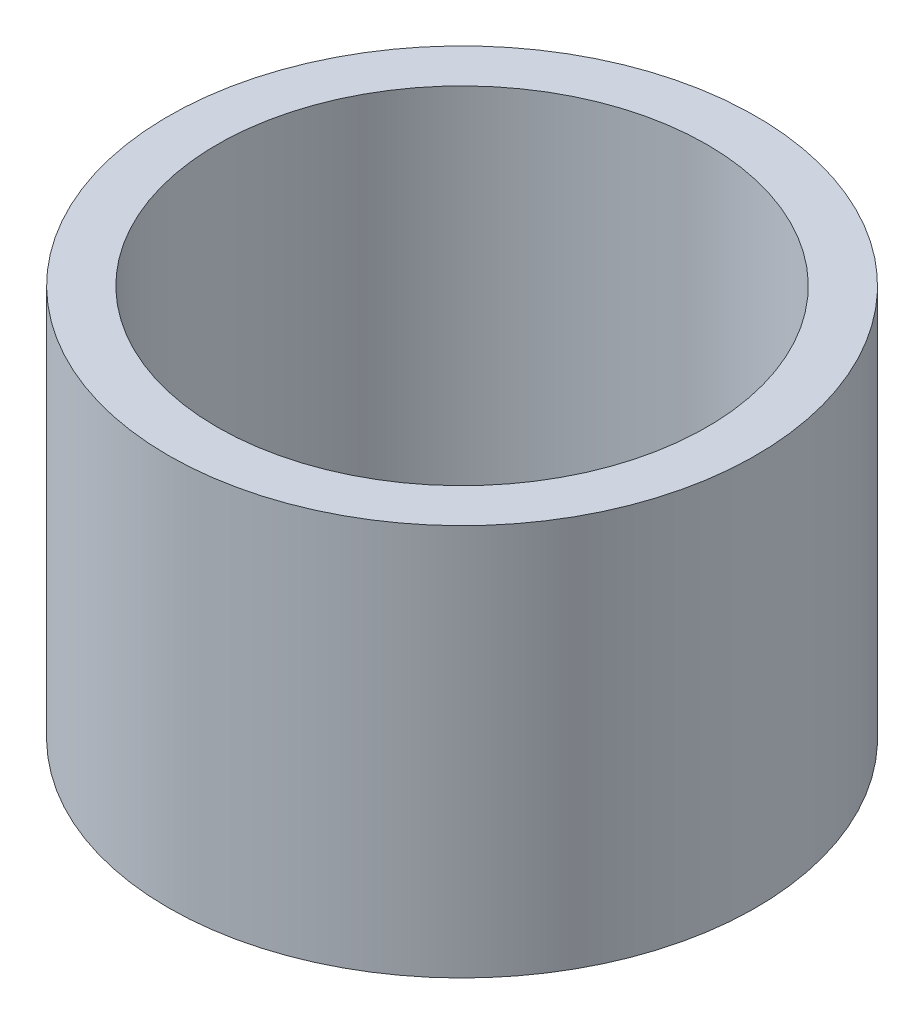
from build123d import *

# Parameters (mm, degrees)
SKETCH16_W         = 60
SKETCH16_H         = 80
SKETCH17_R         = 50
CUT_EXTRUDE3_DEPTH = 100


with BuildPart() as part:
    # Sketch16 → Revolve4 (revolve)
    with BuildSketch(Plane(origin=(0, 0, 0), x_dir=(0, 0, -1), z_dir=(1, 0, 0))):
        with Locations((30, 40)):
            Rectangle(SKETCH16_W, SKETCH16_H)
    revolve(axis=Axis((0, 80, 0), (0, -1, 0)))

    # Sketch17 → Cut-Extrude3 (cut)
    with BuildSketch(Plane(origin=(0, 80, 0), x_dir=(1, 0, 0), z_dir=(0, 1, 0))):
        Circle(SKETCH17_R)
    extrude(amount=-CUT_EXTRUDE3_DEPTH, mode=Mode.SUBTRACT)


solid = part.part
